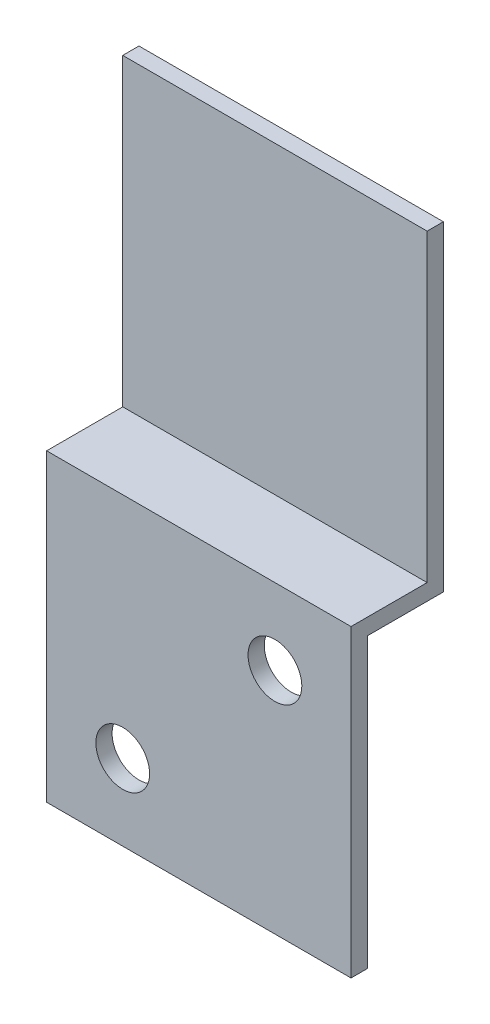
from build123d import *

# Parameters (mm, degrees)
BOSS_EXTRUDE1_DEPTH = 38.1
SKETCH2_R           = 3.3655
CUT_EXTRUDE1_DEPTH  = 12.557


with BuildPart() as part:
    # Sketch1 → Boss-Extrude1 (new body)
    with BuildSketch(Plane(origin=(0, 0, 0), x_dir=(0, 0, -1), z_dir=(1, 0, 0))):
        Polygon((0, 0), (0, -38.1), (-9.525, -38.1), (-9.525, -76.2), (-7.493, -76.2), (-7.493, -40.132), (2.032, -40.132), (2.032, 0), align=None)
    extrude(amount=BOSS_EXTRUDE1_DEPTH)

    # Sketch2 → Cut-Extrude1 (cut, through all)
    with BuildSketch(Plane.XY.offset(9.525)):
        with Locations((9.525, -66.675)):
            Circle(SKETCH2_R)
        with Locations((28.575, -47.625)):
            Circle(SKETCH2_R)
    extrude(amount=-CUT_EXTRUDE1_DEPTH, mode=Mode.SUBTRACT)


solid = part.part
